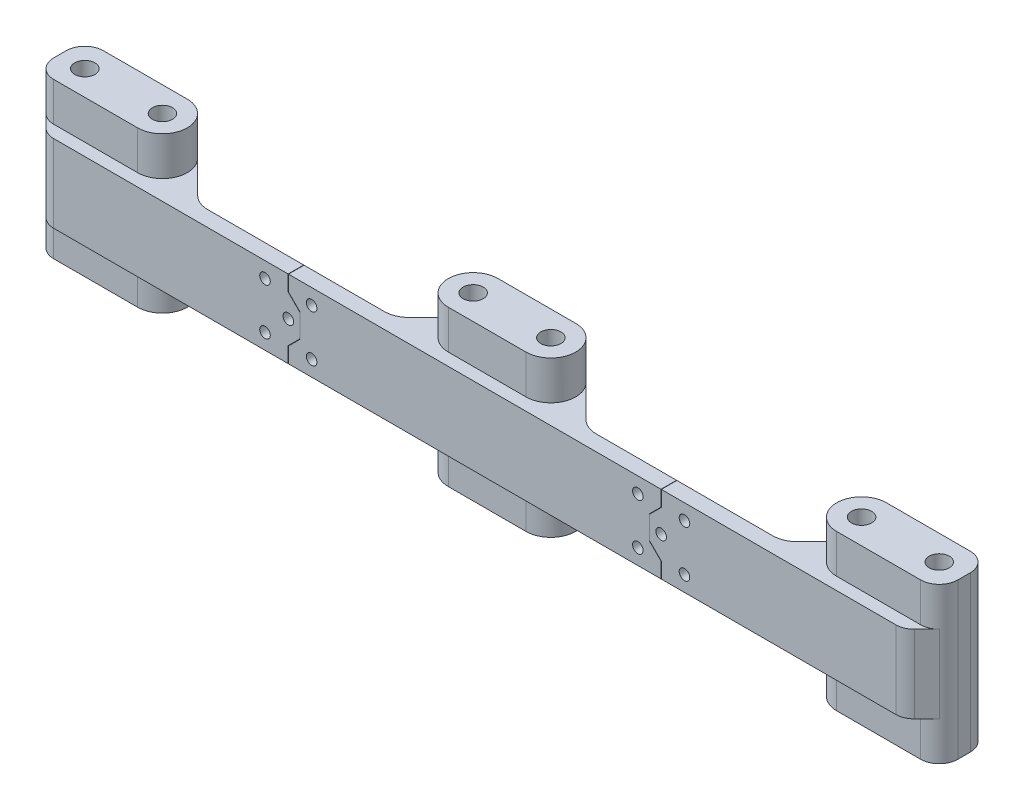
from build123d import *

# Parameters (mm, degrees)
SKETCH1_R                    = 3.25
BOSS_EXTRUDE1_DEPTH          = 12.5
SKETCH1_3_R                  = 3.25
BOSS_EXTRUDE2_DEPTH          = 25
M3_CLEARANCE_HOLE1_D         = 3.4
M3_CLEARANCE_HOLE1_DEPTH     = 8.978536948
M3_CLEARANCE_HOLE1_TIP       = 1.021463052
CUT_EXTRUDE_THIN1_DEPTH      = 149.980703448
CUT_EXTRUDE_THIN1_DEPTH_BACK = 10


with BuildPart() as part:
    # Sketch1 → Boss-Extrude1 (new, symmetric)
    with BuildSketch(Plane(origin=(0, 0, 0), x_dir=(1, 0, 0), z_dir=(0, 1, 0))):
        with BuildLine():
            Line((-135.5, 0), (0, 0))
            Line((0, 0), (0, 20))
            Line((0, 20), (-12.5, 20))
            ThreePointArc((-12.5, 20), (-15.561467459, 19.39103626), (-18.156854249, 17.656854249))
            Line((-18.156854249, 17.656854249), (-28.470562748, 7.343145751))
            ThreePointArc((-28.470562748, 7.343145751), (-31.065949539, 5.60896374), (-34.127416998, 5))
            Line((-34.127416998, 5), (-90.872583002, 5))
            ThreePointArc((-90.872583002, 5), (-93.934050461, 5.60896374), (-96.529437252, 7.343145751))
            Line((-96.529437252, 7.343145751), (-106.843145751, 17.656854249))
            ThreePointArc((-106.843145751, 17.656854249), (-109.438532541, 19.39103626), (-112.5, 20))
            Line((-112.5, 20), (-139.5, 20))
            ThreePointArc((-139.5, 20), (-143.742640687, 18.242640687), (-145.5, 14))
            Line((-145.5, 14), (-145.5, 10))
            ThreePointArc((-145.5, 10), (-145.043277195, 7.703899406), (-143.742640687, 5.757359313))
            Line((-143.742640687, 5.757359313), (-139.742640687, 1.757359313))
            ThreePointArc((-139.742640687, 1.757359313), (-137.796100594, 0.456722805), (-135.5, 0))
        make_face()
        with Locations((-137.5, 12)):
            Circle(SKETCH1_R, mode=Mode.SUBTRACT)
        with Locations((-112.5, 12)):
            Circle(SKETCH1_R, mode=Mode.SUBTRACT)
        with Locations((-12.5, 12)):
            Circle(SKETCH1_R, mode=Mode.SUBTRACT)
    extrude(amount=BOSS_EXTRUDE1_DEPTH, both=True)

    # Sketch1_3 → Boss-Extrude2 (add, symmetric)
    # profile 1 of 2: a face of its own
    with BuildSketch(Plane(origin=(0, 0, 0), x_dir=(1, 0, 0), z_dir=(0, 1, 0))):
        with BuildLine():
            Line((-12.5, 4), (0, 4))
            Line((0, 4), (0, 20))
            Line((0, 20), (-12.5, 20))
            ThreePointArc((-12.5, 20), (-20.5, 12), (-12.5, 4))
        make_face()
        with Locations((-12.5, 12)):
            Circle(SKETCH1_3_R, mode=Mode.SUBTRACT)
    # profile 2 of 2: a face of its own
    with BuildSketch(Plane(origin=(0, 0, 0), x_dir=(1, 0, 0), z_dir=(0, 1, 0))):
        with BuildLine():
            ThreePointArc((-145.5, 10), (-143.742640687, 5.757359313), (-139.5, 4))
            Line((-139.5, 4), (-112.5, 4))
            ThreePointArc((-112.5, 4), (-104.5, 12), (-112.5, 20))
            Line((-112.5, 20), (-139.5, 20))
            ThreePointArc((-139.5, 20), (-143.742640687, 18.242640687), (-145.5, 14))
            Line((-145.5, 14), (-145.5, 10))
        make_face()
        with Locations((-137.5, 12)):
            Circle(SKETCH1_3_R, mode=Mode.SUBTRACT)
        with Locations((-112.5, 12)):
            Circle(SKETCH1_3_R, mode=Mode.SUBTRACT)
    extrude(amount=BOSS_EXTRUDE2_DEPTH, both=True)

    # M3 Clearance Hole1
    with Locations(Plane(origin=(0, 0, -5), x_dir=(-1, 0, 0), z_dir=(0, 0, -1))):
        with Locations((52.5, 7.5), (67.5, 7.5), (60, 0), (67.5, -7.5), (52.5, -7.5)):
            Hole(M3_CLEARANCE_HOLE1_D / 2, depth=M3_CLEARANCE_HOLE1_DEPTH)
            with Locations((0, 0, -(M3_CLEARANCE_HOLE1_DEPTH + M3_CLEARANCE_HOLE1_TIP / 2))):  # 118° drill point
                Cone(0, M3_CLEARANCE_HOLE1_D / 2, M3_CLEARANCE_HOLE1_TIP, mode=Mode.SUBTRACT)

    # Sketch2 → Cut-Extrude-Thin1 (cut, two sides: drawn at the far end of the back side and taken through both)
    with BuildSketch(Plane.XY.offset(-CUT_EXTRUDE_THIN1_DEPTH_BACK)):
        Polygon((-60.05, 12.5), (-60.05, 7.479289322), (-56.3, 3.729289322), (-56.3, -3.729289322), (-60.05, -7.479289322), (-60.05, -12.5), (-59.95, -12.5), (-59.95, -7.520710678), (-56.2, -3.770710678), (-56.2, 3.770710678), (-59.95, 7.520710678), (-59.95, 12.5), align=None)
    extrude(amount=CUT_EXTRUDE_THIN1_DEPTH + CUT_EXTRUDE_THIN1_DEPTH_BACK, mode=Mode.SUBTRACT)


with BuildPart() as cut_extrude_thin1_piece_1:
    # of the separate pieces the step leaves, piece 1, a body of its own (cut_extrude_thin1_pieces)
    add(part.part.solids().sort_by_distance((-139.5, 25, -20))[0])


with BuildPart() as cut_extrude_thin1_piece_2:
    # of the separate pieces the step leaves, piece 2, a body of its own (cut_extrude_thin1_pieces)
    add(part.part.solids().sort_by_distance((-34.127416998, -12.5, -5))[0])


with BuildPart() as body_3:
    # Mirror1: mirrored copy
    add(cut_extrude_thin1_piece_2.part.mirror(Plane(origin=(0, 0, 0), x_dir=(0, 0, 1), z_dir=(1, 0, 0))))


with BuildPart() as body_4:
    # Mirror1 2: mirrored copy
    add(cut_extrude_thin1_piece_1.part.mirror(Plane(origin=(0, 0, 0), x_dir=(0, 0, 1), z_dir=(1, 0, 0))))


with BuildPart() as cut_extrude_thin1_piece_2_1:
    add(cut_extrude_thin1_piece_2.part)

    # Combine1: union body 3
    add(body_3.part)


solid = Compound([cut_extrude_thin1_piece_1.part, body_4.part, cut_extrude_thin1_piece_2_1.part])
